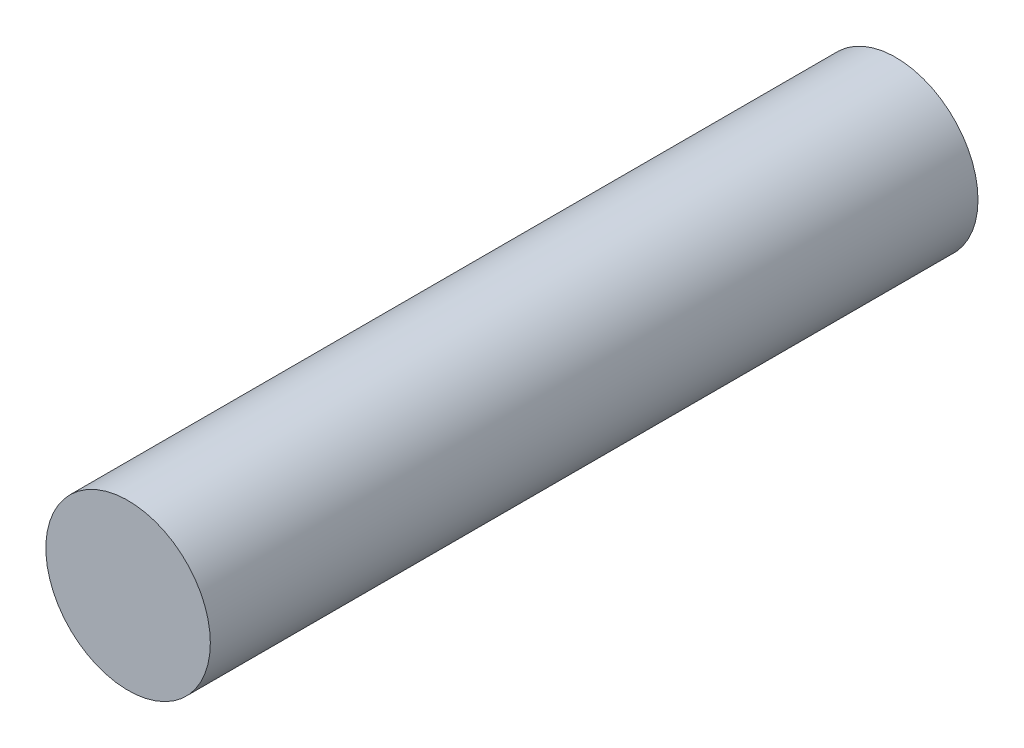
from build123d import *

# Parameters (mm, degrees)
SKETCH1_R           = 1.5
BOSS_EXTRUDE1_DEPTH = 14


with BuildPart() as part:
    # Sketch1 → Boss-Extrude1 (new body)
    with BuildSketch(Plane.XY):
        Circle(SKETCH1_R)
    extrude(amount=BOSS_EXTRUDE1_DEPTH)


solid = part.part
